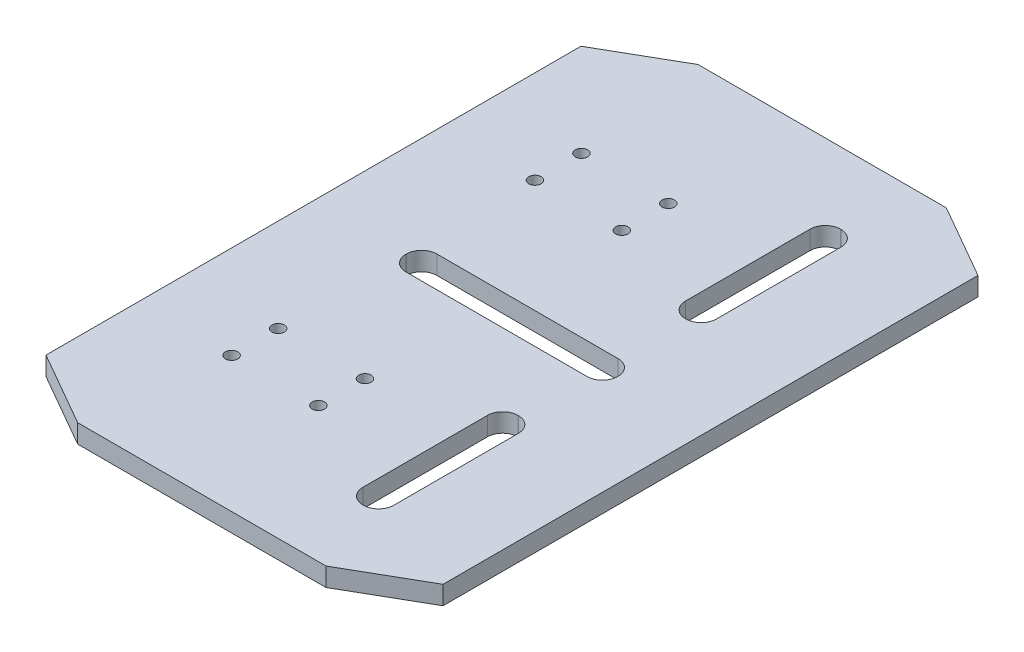
from build123d import *

# Parameters (mm, degrees)
BOSS_EXTRUDE1_DEPTH = 3
CUT_EXTRUDE2_DEPTH  = 10
SKETCH7_R           = 1
CUT_EXTRUDE3_DEPTH  = 11.5


with BuildPart() as part:
    # Sketch1 → Boss-Extrude1 (new body)
    with BuildSketch(Plane(origin=(0, 0, 0), x_dir=(1, 0, 0), z_dir=(0, 1, 0))):
        Polygon((-32, -43.117707706), (-20.011895516, -50), (20.011895516, -50), (32, -43.117707706), (32, 43.117707706), (20.011895516, 50), (-20.011895516, 50), (-32, 43.117707706), align=None)
    extrude(amount=BOSS_EXTRUDE1_DEPTH)

    # Sketch5 → Cut-Extrude2 (cut)
    with BuildSketch(Plane(origin=(0, 3, 0), x_dir=(1, 0, 0), z_dir=(0, 1, 0))):
        with BuildLine():
            Line((-14.620176413, -2.5), (14.620176413, -2.5))
            ThreePointArc((14.620176413, -2.5), (16.352588027, -1.782411614), (17.070176413, -0.05))
            Line((17.070176413, -0.05), (17.070176413, 0.05))
            ThreePointArc((17.070176413, 0.05), (16.352588027, 1.782411614), (14.620176413, 2.5))
            Line((14.620176413, 2.5), (-14.620176413, 2.5))
            ThreePointArc((-14.620176413, 2.5), (-16.352588027, 1.782411614), (-17.070176413, 0.05))
            Line((-17.070176413, 0.05), (-17.070176413, -0.05))
            ThreePointArc((-17.070176413, -0.05), (-16.352588027, -1.782411614), (-14.620176413, -2.5))
        make_face()
        with BuildLine():
            Line((14.45, -38.5), (14.55, -38.5))
            ThreePointArc((14.55, -38.5), (16.282411614, -37.782411614), (17, -36.05))
            Line((17, -36.05), (17, -15.95))
            ThreePointArc((17, -15.95), (16.282411614, -14.217588386), (14.55, -13.5))
            Line((14.55, -13.5), (14.45, -13.5))
            ThreePointArc((14.45, -13.5), (12.717588386, -14.217588386), (12, -15.95))
            Line((12, -15.95), (12, -36.05))
            ThreePointArc((12, -36.05), (12.717588386, -37.782411614), (14.45, -38.5))
        make_face()
        with BuildLine():
            Line((14.45, 13.5), (14.55, 13.5))
            ThreePointArc((14.55, 13.5), (16.282411614, 14.217588386), (17, 15.95))
            Line((17, 15.95), (17, 36.05))
            ThreePointArc((17, 36.05), (16.282411614, 37.782411614), (14.55, 38.5))
            Line((14.55, 38.5), (14.45, 38.5))
            ThreePointArc((14.45, 38.5), (12.717588386, 37.782411614), (12, 36.05))
            Line((12, 36.05), (12, 15.95))
            ThreePointArc((12, 15.95), (12.717588386, 14.217588386), (14.45, 13.5))
        make_face()
    extrude(amount=-CUT_EXTRUDE2_DEPTH, mode=Mode.SUBTRACT)

    # Sketch7 → Cut-Extrude3 (cut)
    with BuildSketch(Plane(origin=(0, 3, 0), x_dir=(1, 0, 0), z_dir=(0, 1, 0))):
        with Locations((-3, 28.2)):
            Circle(SKETCH7_R)
        with Locations((-3, 20.7)):
            Circle(SKETCH7_R)
        with Locations((-17, 20.7)):
            Circle(SKETCH7_R)
        with Locations((-17, 28.2)):
            Circle(SKETCH7_R)
    cut_extrude3 = extrude(amount=-CUT_EXTRUDE3_DEPTH, mode=Mode.SUBTRACT)

    # Mirror1: Cut-Extrude3 across plane
    add(cut_extrude3.mirror(Plane(origin=(0, 0, 0), x_dir=(1, 0, 0), z_dir=(0, 0, -1))), mode=Mode.SUBTRACT)


solid = part.part
